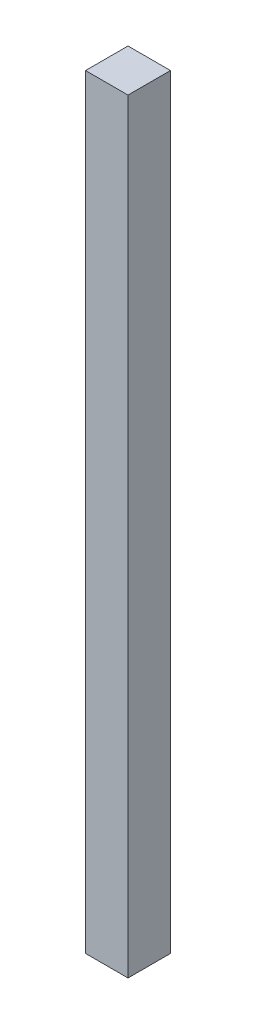
from build123d import *

# Parameters (mm, degrees)
SKETCH1_W           = 25.4
SKETCH1_H           = 25.4
BOSS_EXTRUDE1_DEPTH = 457.2


with BuildPart() as part:
    # Sketch1 → Boss-Extrude1 (new body)
    with BuildSketch(Plane(origin=(0, 0, 0), x_dir=(1, 0, 0), z_dir=(0, 1, 0))):
        with Locations((12.7, 12.7)):
            Rectangle(SKETCH1_W, SKETCH1_H)
    extrude(amount=BOSS_EXTRUDE1_DEPTH)


solid = part.part
